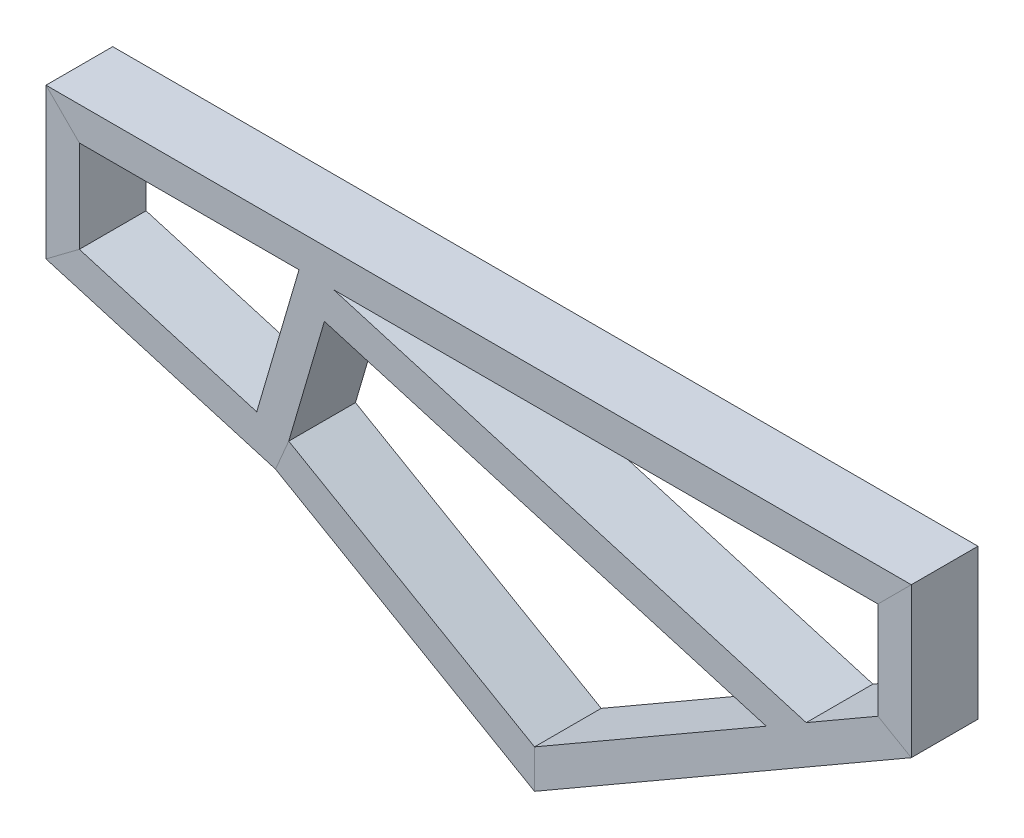
from build123d import *

# Parameters (mm, degrees)
SKETCH_6_W      = 80
SKETCH_6_H      = 40
SKETCH_6_W_2    = 76
SKETCH_6_H_2    = 36
SKETCH_14_W     = 40
SKETCH_14_H     = 80
EXTRUDE_1_DEPTH = 194
SKETCH_15_W     = 80
SKETCH_15_H     = 40
EXTRUDE_2_DEPTH = 595


with BuildPart() as part:
    # По траектории13: sweep along a curve in space
    with BuildLine() as sweep_13_path:
        Line((0, 0, 0), (1000, 0, 0))
        Line((1000, 0, 0), (1000, -150, 0))
        Line((1000, -150, 0), (566.987298108, -400, 0))
        Line((566.987298108, -400, 0), (263.878406783, -225, 0))
        Line((263.878406783, -225, 0), (0, -147.584326952, 0))
        Line((0, -147.584326952, 0), (0, 0, 0))
    # Эскиз6 → По траектории13 (sweep)
    with BuildSketch(Plane(origin=(0, 0, 0), x_dir=(0, 0, -1), z_dir=(1, 0, 0))):
        with Locations((-0.551773823, -1.216505436)):
            Rectangle(SKETCH_6_W, SKETCH_6_H)
        with Locations((-0.551773823, -1.216505436)):
            Rectangle(SKETCH_6_W_2, SKETCH_6_H_2, mode=Mode.SUBTRACT)
    sweep(path=sweep_13_path.line, transition=Transition.RIGHT)

    # Эскиз14 → Бобышка-Вытянуть1 (add)
    with BuildSketch(Plane(origin=(-33.89376203, -115.529989888, 0), x_dir=(0.9595578428480989, -0.2815115383580276, 0), z_dir=(0.2815115383580276, 0.9595578428480989, 0))):
        with Locations((299.085913187, -0.551773823)):
            Rectangle(SKETCH_14_W, SKETCH_14_H)
    extrude(amount=EXTRUDE_1_DEPTH)

    # Эскиз15 → Бобышка-Вытянуть2 (add)
    with BuildSketch(Plane(origin=(306.181390541, -89.82636629, 0), x_dir=(0, 0, -1), z_dir=(0.9595578428480989, -0.28151153835802767, 0))):
        with Locations((-0.551773823, 51.50143726)):
            Rectangle(SKETCH_15_W, SKETCH_15_H)
    extrude(amount=EXTRUDE_2_DEPTH)


solid = part.part
